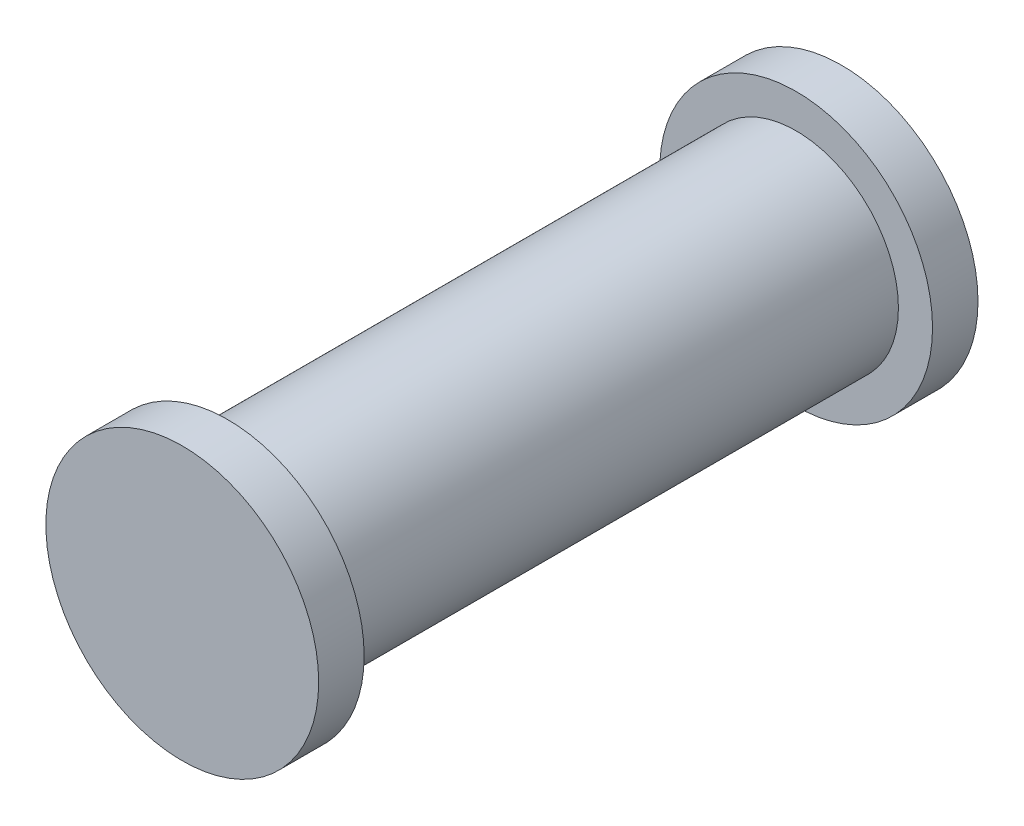
from build123d import *

# Parameters (mm, degrees)
SKETCH1_R           = 4.5
BOSS_EXTRUDE1_DEPTH = 25
SKETCH2_R           = 6
BOSS_EXTRUDE2_DEPTH = 2
SKETCH3_R           = 6
BOSS_EXTRUDE3_DEPTH = 2


with BuildPart() as part:
    # Sketch1 → Boss-Extrude1 (new body)
    with BuildSketch(Plane.XY):
        Circle(SKETCH1_R)
    extrude(amount=BOSS_EXTRUDE1_DEPTH)

    # Sketch2 → Boss-Extrude2 (add)
    with BuildSketch(Plane.XY):
        Circle(SKETCH2_R)
    extrude(amount=-BOSS_EXTRUDE2_DEPTH)

    # Sketch3 → Boss-Extrude3 (add)
    with BuildSketch(Plane.XY.offset(25)):
        Circle(SKETCH3_R)
    extrude(amount=BOSS_EXTRUDE3_DEPTH)


solid = part.part
